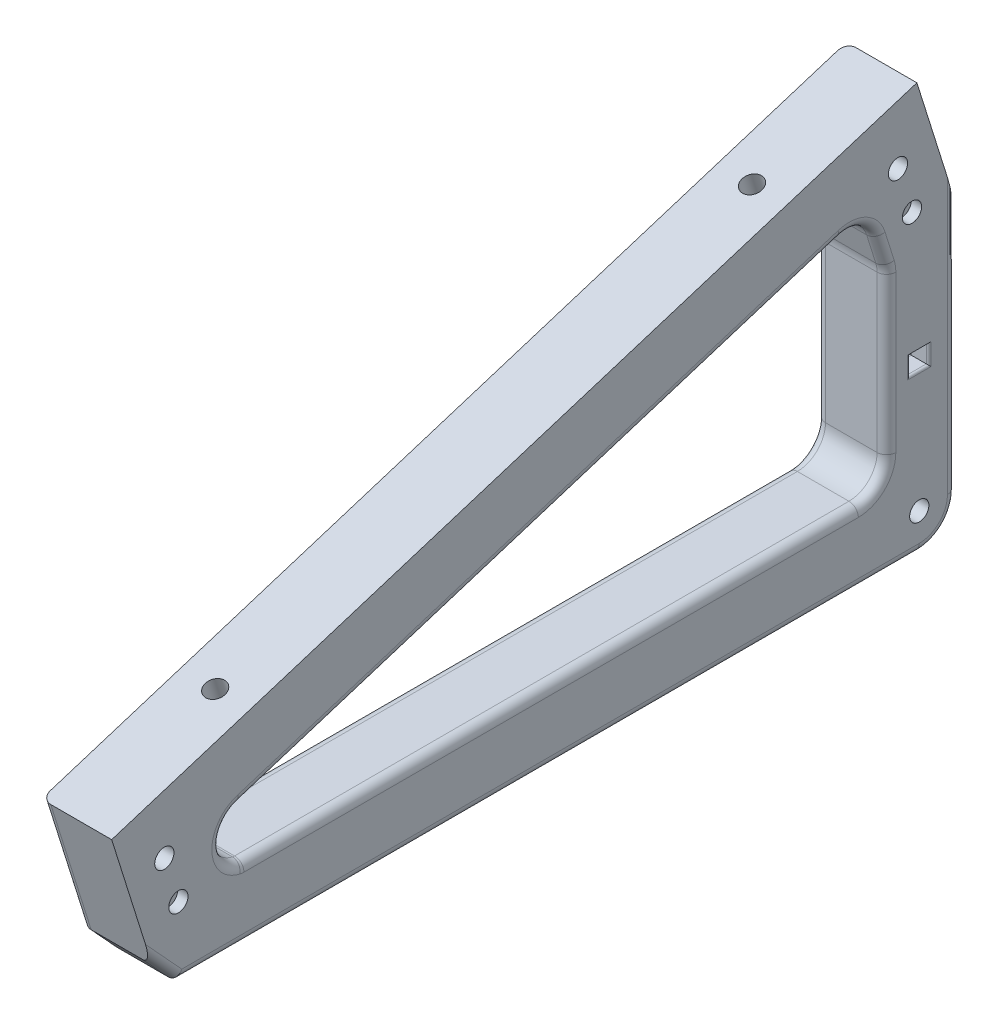
from build123d import *

# Parameters (mm, degrees)
BOSS_EXTRUDE1_DEPTH = 15
CUT_EXTRUDE1_REACH  = 210.672
SKETCH3_R           = 2.1
CUT_EXTRUDE2_DEPTH  = 8
SKETCH5_R           = 2.05
CUT_EXTRUDE3_DEPTH  = 211.29194948
SKETCH5_3_R         = 4
SKETCH5_3_R_2       = 2.05
CUT_EXTRUDE4_DEPTH  = 3
SKETCH6_R           = 2.05
CUT_EXTRUDE5_DEPTH  = 2.2
FILLET1_R           = 2
SKETCH7_W           = 4
SKETCH7_H           = 4.1
CUT_EXTRUDE6_DEPTH  = 4.2
FILLET2_R           = 0.5


with BuildPart() as part:
    # Sketch2 → Boss-Extrude1 (new body)
    with BuildSketch(Plane(origin=(0, 0, 0), x_dir=(0, 0, -1), z_dir=(1, 0, 0))):
        with BuildLine():
            ThreePointArc((182.713463258, 0), (188.370317508, 2.343145751), (190.713463258, 8))
            Line((190.713463258, 8), (190.713463258, 60.22857568))
            Line((190.713463258, 60.22857568), (182.203249602, 87.327423803))
            Line((182.203249602, 87.327423803), (10.472480761, 33.39651399))
            Line((10.472480761, 33.39651399), (19.096918934, 5.933943762))
            Line((19.096918934, 5.933943762), (24.551301688, 0))
            Line((24.551301688, 0), (182.713463258, 0))
        make_face()
        with BuildLine():
            Line((37.938354626, 26.299705178), (165.973133125, 66.508178818))
            ThreePointArc((165.973133125, 66.508178818), (170.547399424, 66.102716631), (173.49518908, 62.58151685))
            Line((173.49518908, 62.58151685), (175.43782222, 56.395641556))
            ThreePointArc((175.43782222, 56.395641556), (175.644152669, 55.507297693), (175.713463258, 54.597944563))
            Line((175.713463258, 54.597944563), (175.713463258, 21.281778339))
            ThreePointArc((175.713463258, 21.281778339), (173.956103945, 17.039137651), (169.713463258, 15.281778339))
            Line((169.713463258, 15.281778339), (38.483983749, 15.281778339))
            ThreePointArc((38.483983749, 15.281778339), (33.847693688, 20.428280139), (37.659397671, 26.212100595))
            ThreePointArc((37.659397671, 26.212100595), (37.798310715, 26.257703381), (37.938354626, 26.299705178))
        make_face(mode=Mode.SUBTRACT)
    extrude(amount=BOSS_EXTRUDE1_DEPTH)

    # Sketch3 → Cut-Extrude1 (cut, up to next)
    with BuildSketch(Plane(origin=(0, 27.404937127, 8.606338879), x_dir=(1, 0, 0), z_dir=(0, 0.9540598268960737, 0.2996161656236761)), mode=Mode.PRIVATE) as cut_extrude1_sk1:
        with Locations((7.5, 170.997508649)):
            Circle(SKETCH3_R)
    cut_extrude1_tool1 = extrude(cut_extrude1_sk1.sketch, amount=-CUT_EXTRUDE1_REACH, mode=Mode.PRIVATE) & part.part
    # Sketch3 → Cut-Extrude1 (cut, up to next)
    with BuildSketch(Plane(origin=(0, 27.404937127, 8.606338879), x_dir=(1, 0, 0), z_dir=(0, 0.9540598268960737, 0.2996161656236761)), mode=Mode.PRIVATE) as cut_extrude1_sk2:
        with Locations((7.5, 50.997508649)):
            Circle(SKETCH3_R)
    cut_extrude1_tool2 = extrude(cut_extrude1_sk2.sketch, amount=-CUT_EXTRUDE1_REACH, mode=Mode.PRIVATE) & part.part
    add(cut_extrude1_tool1.solids().sort_by_distance((7.5, 78.638555, -154.535515))[0], mode=Mode.SUBTRACT)
    add(cut_extrude1_tool2.solids().sort_by_distance((7.5, 42.684615, -40.048335))[0], mode=Mode.SUBTRACT)

    # Sketch4 → Cut-Extrude2 (cut)
    with BuildSketch(Plane(origin=(0, 13.094039723, 4.112096395), x_dir=(1, 0, 0), z_dir=(0, -0.9540598268960736, -0.2996161656236761))):
        Polygon((3.910348885, -172.976836364), (7.419322526, -175.095901563), (11.008973641, -173.116573848), (11.089651115, -169.018180934), (7.580677474, -166.899115735), (3.991026359, -168.87844345), align=None)
        Polygon((7.302343544, -46.903089855), (3.855301083, -49.121474764), (4.052957539, -53.215893558), (7.697656456, -55.091927443), (11.144698917, -52.873542534), (10.947042461, -48.77912374), align=None)
    extrude(amount=-CUT_EXTRUDE2_DEPTH, mode=Mode.SUBTRACT)

    # Sketch5 → Cut-Extrude3 (cut, through all)
    with BuildSketch(Plane.ZY):
        with Locations((-178.166164975, 73.481776555)):
            Circle(SKETCH5_R)
        with Locations((-182.713463258, 8)):
            Circle(SKETCH5_R)
        with Locations((-21.700353364, 24.344725393)):
            Circle(SKETCH5_R)
    extrude(amount=-CUT_EXTRUDE3_DEPTH, mode=Mode.SUBTRACT)

    # Sketch5_3 → Cut-Extrude4 (cut)
    # profile 1 of 3: a face of its own
    with BuildSketch(Plane.ZY):
        with Locations((-178.166164975, 73.481776555)):
            Circle(SKETCH5_3_R)
    # profile 2 of 3: a face of its own
    with BuildSketch(Plane.ZY):
        with Locations((-182.713463258, 8)):
            Circle(SKETCH5_3_R)
        with Locations((-182.713463258, 8)):
            Circle(SKETCH5_3_R_2, mode=Mode.SUBTRACT)
    # profile 3 of 3: a face of its own
    with BuildSketch(Plane.ZY):
        with Locations((-21.700353364, 24.344725393)):
            Circle(SKETCH5_3_R)
    extrude(amount=-CUT_EXTRUDE4_DEPTH, mode=Mode.SUBTRACT)

    # Sketch6 → Cut-Extrude5 (cut)
    with BuildSketch(Plane(origin=(15, 0, 0), x_dir=(0, 0, -1), z_dir=(1, 0, 0))):
        with Locations((24.69651502, 14.804127124)):
            Circle(SKETCH6_R)
        with Locations((181.162326631, 63.941178286)):
            Circle(SKETCH6_R)
    extrude(amount=-CUT_EXTRUDE5_DEPTH, mode=Mode.SUBTRACT)

    # Fillet1
    fillet1_edges = [part.edges().sort_by_distance(p)[0] for p in [
        (15, 46.403941998, -101.955743876),
        (15, 66.102716631, -170.547399424),
        (15, 59.488579203, -174.46650565),
        (15, 55.507297693, -175.644152669),
        (15, 37.939861451, -175.713463258),
        (15, 17.039137651, -173.956103945),
        (0, 46.403941998, -101.955743876),
        (0, 66.102716631, -170.547399424),
        (0, 59.488579203, -174.46650565),
        (0, 55.507297693, -175.644152669),
        (0, 37.939861451, -175.713463258),
        (0, 17.039137651, -173.956103945),
        (0, 2.343145751, -188.370317508),
        (15, 15.281778339, -104.098723504),
        (0, 15.281778339, -104.098723504),
        (0, 19.665228876, -14.784699847),
        (0, 34.11428784, -190.713463258),
        (0, 73.777999741, -186.45835643),
        (15, 34.11428784, -190.713463258),
        (15, 2.343145751, -188.370317508),
        (15, 20.574202547, -33.838577822),
        (0, 20.574202547, -33.838577822),
        (0, 0, -103.632382473),
        (7.5, 15.281778339, -38.483983749),
        (15, 2.966971881, -21.824110311),
        (15, 0, -103.632382473),
        (0, 2.966971881, -21.824110311),
    ]]
    fillet(fillet1_edges, radius=FILLET1_R)

    # Sketch7 → Cut-Extrude6 (cut)
    with BuildSketch(Plane(origin=(15, 0, 0), x_dir=(0, 0, -1), z_dir=(1, 0, 0))):
        with Locations((182.713463258, 35.95)):
            Rectangle(SKETCH7_W, SKETCH7_H)
    extrude(amount=-CUT_EXTRUDE6_DEPTH, mode=Mode.SUBTRACT)

    # Fillet2
    fillet2_edges = [part.edges().sort_by_distance(p)[0] for p in [
        (10.8, 35.95, -184.713463258),
        (10.8, 38, -182.713463258),
        (10.8, 35.95, -180.713463258),
        (10.8, 33.9, -182.713463258),
        (15, 35.95, -180.713463258),
        (15, 33.9, -182.713463258),
        (15, 35.95, -184.713463258),
    ]]
    fillet(fillet2_edges, radius=FILLET2_R)


solid = part.part
